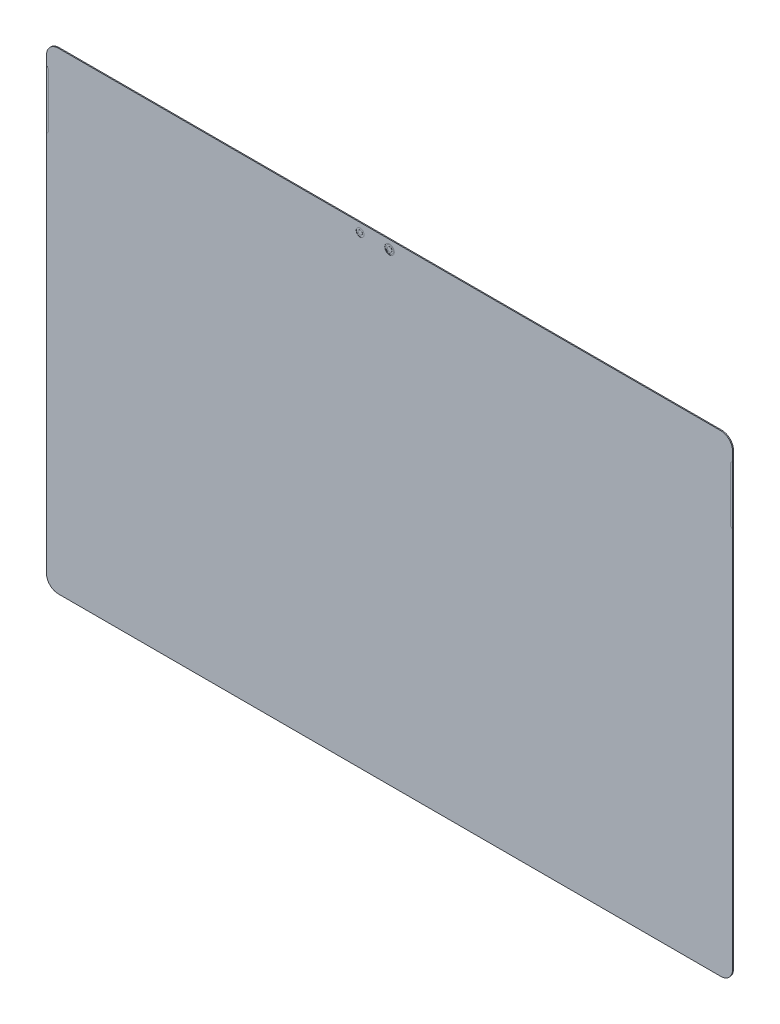
from build123d import *

# Parameters (mm, degrees)
BOSS_EXTRUDE1_DEPTH = 0.45
SKETCH3_R           = 2.2
SKETCH3_R_2         = 1.8
CUT_EXTRUDE1_DEPTH  = 0.1
SKETCH4_R           = 0.950130495
BOSS_EXTRUDE2_DEPTH = 0.05
SKETCH5_R           = 1.775413814
CUT_EXTRUDE2_DEPTH  = 0.05
SKETCH6_R           = 1.05635073
BOSS_EXTRUDE3_DEPTH = 0.08
BOSS_EXTRUDE5_DEPTH = 0.01


with BuildPart() as part:
    # Sketch1 → Boss-Extrude1 (new body)
    with BuildSketch(Plane.XY):
        with BuildLine():
            Line((-152.1, -108.5), (152.1, -108.5))
            ThreePointArc((152.1, -108.5), (155.918376618, -106.918376618), (157.5, -103.1))
            Line((157.5, -103.1), (157.5, 103.1))
            ThreePointArc((157.5, 103.1), (155.918376618, 106.918376618), (152.1, 108.5))
            Line((152.1, 108.5), (-152.1, 108.5))
            ThreePointArc((-152.1, 108.5), (-155.918376618, 106.918376618), (-157.5, 103.1))
            Line((-157.5, 103.1), (-157.5, -103.1))
            ThreePointArc((-157.5, -103.1), (-155.918376618, -106.918376618), (-152.1, -108.5))
        make_face()
    extrude(amount=BOSS_EXTRUDE1_DEPTH)

    # Sketch3 → Cut-Extrude1 (cut)
    with BuildSketch(Plane.XY.offset(0.45)):
        with Locations((0, 104.5)):
            Circle(SKETCH3_R)
        with Locations((-13.5, 104.5)):
            Circle(SKETCH3_R_2)
    extrude(amount=-CUT_EXTRUDE1_DEPTH, mode=Mode.SUBTRACT)

    # Sketch4 → Boss-Extrude2 (add)
    with BuildSketch(Plane.XY.offset(0.35)):
        with Locations((-13.5, 104.5)):
            Circle(SKETCH4_R)
    extrude(amount=BOSS_EXTRUDE2_DEPTH)

    # Sketch5 → Cut-Extrude2 (cut)
    with BuildSketch(Plane.XY.offset(0.35)):
        with Locations((0, 104.5)):
            Circle(SKETCH5_R)
    extrude(amount=-CUT_EXTRUDE2_DEPTH, mode=Mode.SUBTRACT)

    # Sketch6 → Boss-Extrude3 (add)
    with BuildSketch(Plane.XY.offset(0.3)):
        with Locations((0, 104.5)):
            Circle(SKETCH6_R)
    extrude(amount=BOSS_EXTRUDE3_DEPTH)

    # Sketch7 → Boss-Extrude5 (add)
    with BuildSketch(Plane.XY.offset(0.45)):
        with BuildLine():
            Line((157.5, 71.944818632), (156.792893219, 72.651925413))
            ThreePointArc((156.792893219, 72.651925413), (156.576120467, 72.976348762), (156.5, 73.359032194))
            Line((156.5, 73.359032194), (156.5, 97.530605069))
            ThreePointArc((156.5, 97.530605069), (156.576120467, 97.913288502), (156.792893219, 98.23771185))
            Line((156.792893219, 98.23771185), (157.5, 98.944818632))
            Line((157.5, 98.944818632), (157.5, 71.944818632))
        make_face()
        with BuildLine():
            Line((-157.5, 98.944818632), (-157.5, 71.944818632))
            Line((-157.5, 71.944818632), (-156.792893219, 72.651925413))
            ThreePointArc((-156.792893219, 72.651925413), (-156.576120467, 72.976348762), (-156.5, 73.359032194))
            Line((-156.5, 73.359032194), (-156.5, 97.530605069))
            ThreePointArc((-156.5, 97.530605069), (-156.576120467, 97.913288502), (-156.792893219, 98.23771185))
            Line((-156.792893219, 98.23771185), (-157.5, 98.944818632))
        make_face()
    extrude(amount=BOSS_EXTRUDE5_DEPTH)


solid = part.part
